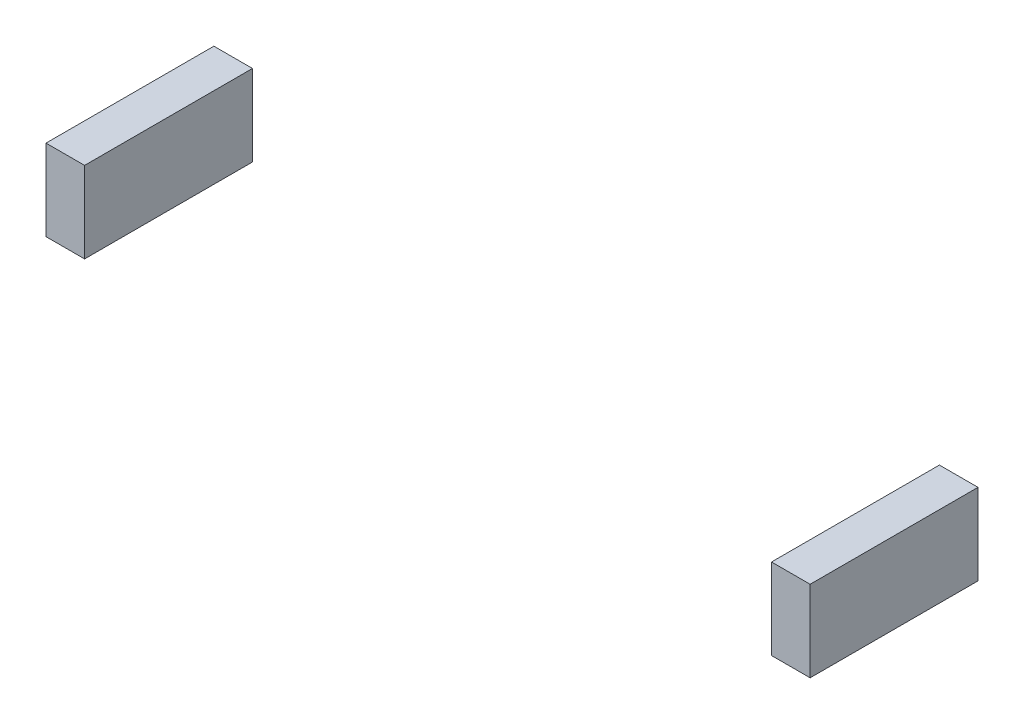
from build123d import *

# Parameters (mm, degrees)
SKETCH1_W        = 1000
SKETCH1_H        = 4350
EXTRUDE1_DEPTH   = 2100
EXTRUDE1_2_DEPTH = 2100


with BuildPart() as part:
    # Sketch1 → Extrude1 (new body)
    with BuildSketch(Plane.XZ.offset(2362)):
        with Locations((9400, 0)):
            Rectangle(SKETCH1_W, SKETCH1_H)
    extrude(amount=EXTRUDE1_DEPTH)


with BuildPart() as body_2:
    # Sketch1 → Extrude1 2 (new body)
    with BuildSketch(Plane.XZ.offset(2362)):
        with Locations((-9400, 0)):
            Rectangle(SKETCH1_W, SKETCH1_H)
    extrude(amount=EXTRUDE1_2_DEPTH)


solid = Compound([part.part, body_2.part])
